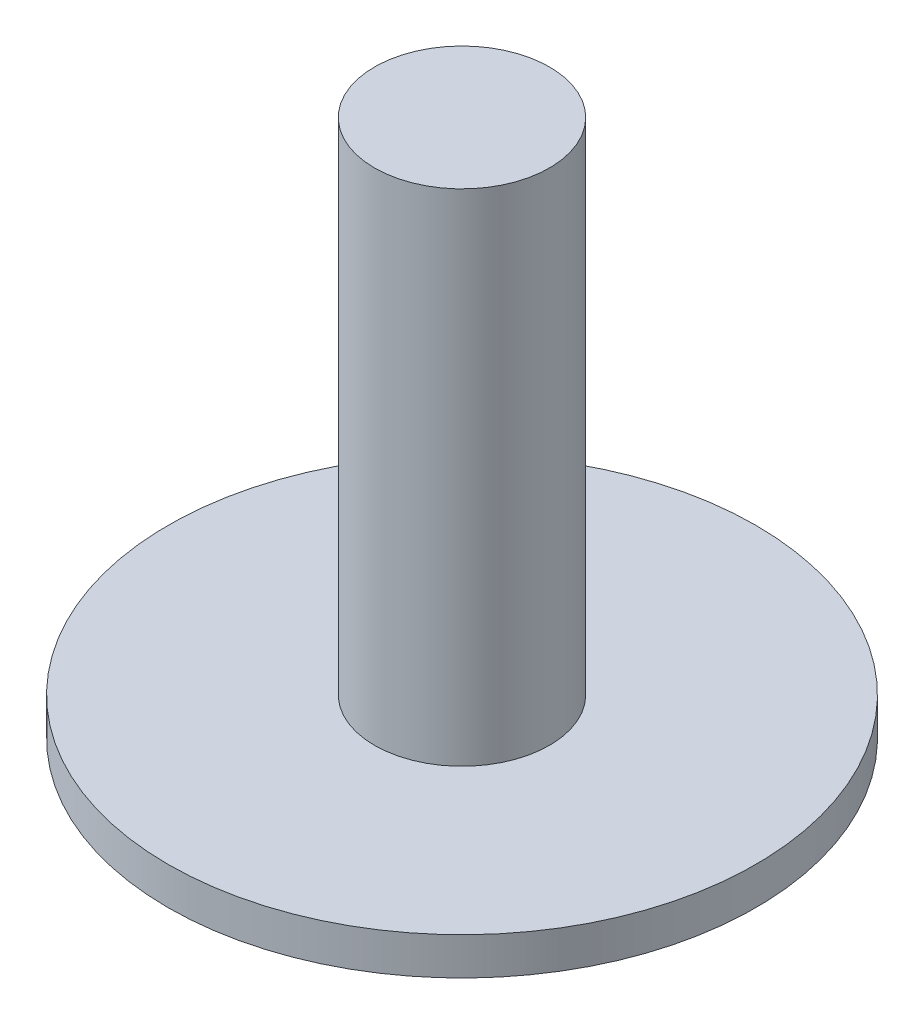
from build123d import *

# Parameters (mm, degrees)
SKETCH1_R           = 11.75
BOSS_EXTRUDE1_DEPTH = 1.5
SKETCH2_R           = 3.5
BOSS_EXTRUDE2_DEPTH = 20


with BuildPart() as part:
    # Sketch1 → Boss-Extrude1 (new body)
    with BuildSketch(Plane(origin=(0, 0, 0), x_dir=(1, 0, 0), z_dir=(0, 1, 0))):
        Circle(SKETCH1_R)
    extrude(amount=BOSS_EXTRUDE1_DEPTH)

    # Sketch2 → Boss-Extrude2 (add)
    with BuildSketch(Plane(origin=(0, 1.5, 0), x_dir=(1, 0, 0), z_dir=(0, 1, 0))):
        Circle(SKETCH2_R)
    extrude(amount=BOSS_EXTRUDE2_DEPTH)


solid = part.part
